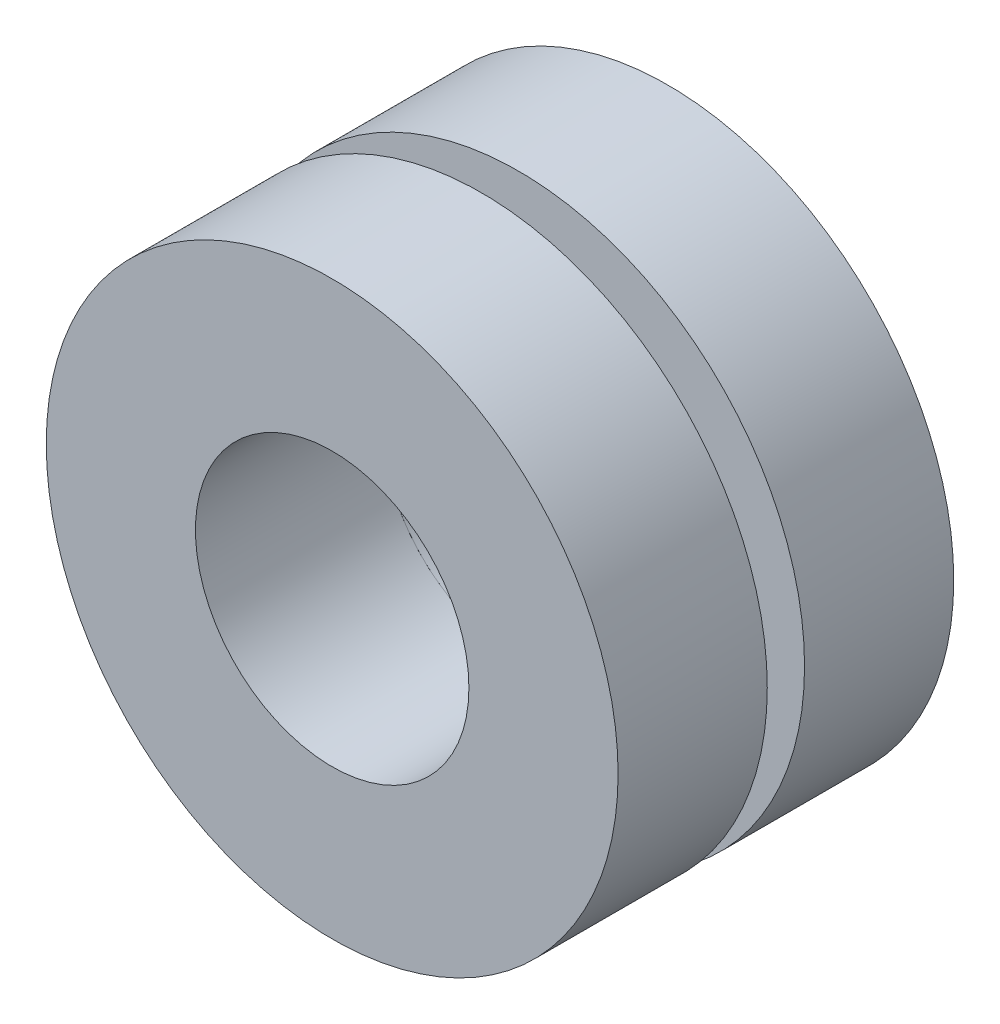
from build123d import *

# Parameters (mm, degrees)
SKETCH1_R           = 4.572
SKETCH1_R_2         = 2.794
BOSS_EXTRUDE2_DEPTH = 0.762
SKETCH3_R           = 5.842
SKETCH3_R_2         = 2.794
BOSS_EXTRUDE3_DEPTH = 3.048
SKETCH4_R           = 5.842
SKETCH4_R_2         = 2.794
BOSS_EXTRUDE4_DEPTH = 3.048


with BuildPart() as part:
    # Sketch1 → Boss-Extrude2 (new body)
    with BuildSketch(Plane.XY):
        Circle(SKETCH1_R)
        Circle(SKETCH1_R_2, mode=Mode.SUBTRACT)
    extrude(amount=BOSS_EXTRUDE2_DEPTH)

    # Sketch3 → Boss-Extrude3 (add)
    with BuildSketch(Plane.XY.offset(0.762)):
        Circle(SKETCH3_R)
        Circle(SKETCH3_R_2, mode=Mode.SUBTRACT)
    extrude(amount=BOSS_EXTRUDE3_DEPTH)


with BuildPart() as body_2:
    # Sketch4 → Boss-Extrude4 (new body)
    with BuildSketch(Plane(origin=(0, 0, 0), x_dir=(-1, 0, 0), z_dir=(0, 0, -1))):
        Circle(SKETCH4_R)
        Circle(SKETCH4_R_2, mode=Mode.SUBTRACT)
    extrude(amount=BOSS_EXTRUDE4_DEPTH)


solid = Compound([part.part, body_2.part])
